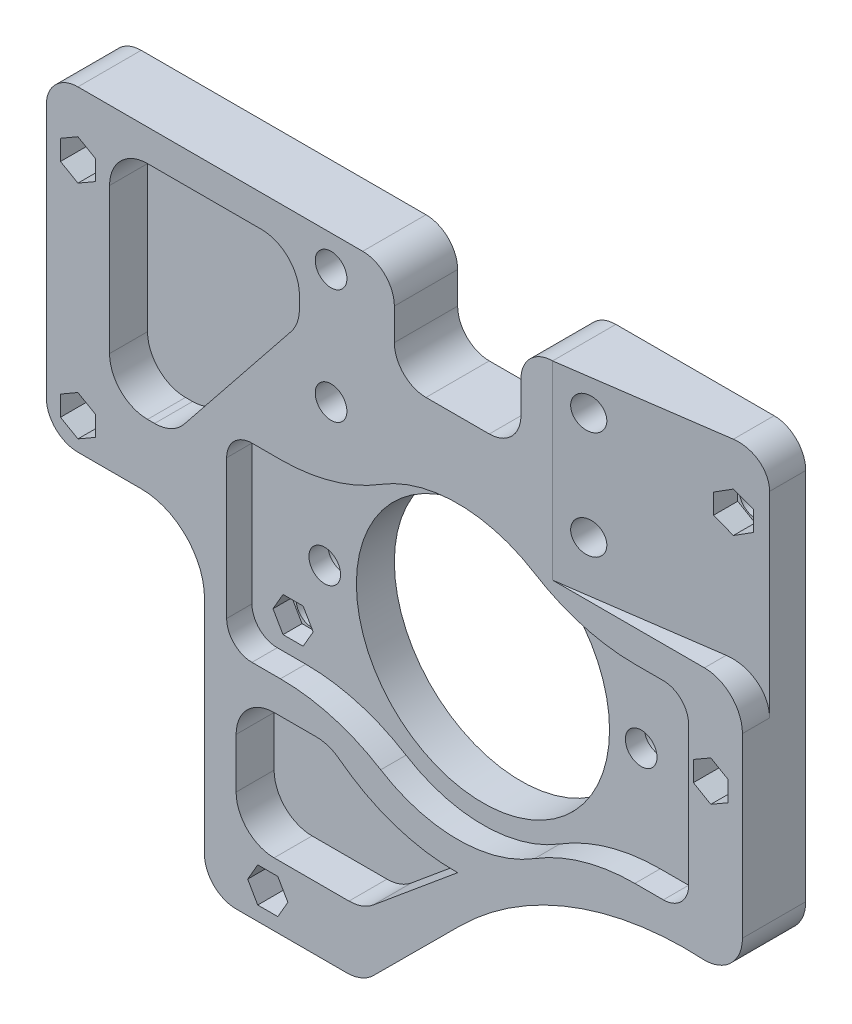
from build123d import *

# Parameters (mm, degrees)
SKETCH1_R           = 20
SKETCH1_R_2         = 2.5
BOSS_EXTRUDE1_DEPTH = 10
CUT_EXTRUDE1_DEPTH  = 30
FILLET1_R           = 6
CUT_EXTRUDE2_DEPTH  = 4
CUT_EXTRUDE3_DEPTH  = 6
SKETCH5_R           = 3.75
CUT_EXTRUDE4_DEPTH  = 3
CUT_EXTRUDE5_DEPTH  = 5
CUT_EXTRUDE6_DEPTH  = 7


with BuildPart() as part:
    # Sketch1 → Boss-Extrude1 (new body)
    with BuildSketch(Plane.XY):
        with BuildLine():
            Line((0, 5), (0, 40))
            ThreePointArc((0, 40), (-2.928932188, 47.071067812), (-10, 50))
            Line((-10, 50), (-20, 50))
            ThreePointArc((-20, 50), (-23.535533906, 51.464466094), (-25, 55))
            Line((-25, 55), (-25, 95))
            ThreePointArc((-25, 95), (-23.535533906, 98.535533906), (-20, 100))
            Line((-20, 100), (25, 100))
            ThreePointArc((25, 100), (28.535533906, 98.535533906), (30, 95))
            Line((30, 95), (30, 90))
            ThreePointArc((30, 90), (31.464466094, 86.464466094), (35, 85))
            Line((35, 85), (45, 85))
            ThreePointArc((45, 85), (48.535533906, 86.464466094), (50, 90))
            Line((50, 90), (50, 95))
            ThreePointArc((50, 95), (51.464466094, 98.535533906), (55, 100))
            Line((55, 100), (80, 100))
            ThreePointArc((80, 100), (83.535533906, 98.535533906), (85, 95))
            Line((85, 95), (85, 36))
            ThreePointArc((85, 36), (83.242640687, 31.757359313), (79, 30))
            ThreePointArc((79, 30), (58.114182378, 26.808820785), (40.36, 15.355))
            Line((40.36, 15.355), (26.706048875, 1.749781342))
            ThreePointArc((26.706048875, 1.749781342), (24.762144416, 0.4546726), (22.470999719, 0))
            Line((22.470999719, 0), (5, 0))
            ThreePointArc((5, 0), (1.464466094, 1.464466094), (0, 5))
        make_face()
        with Locations((40, 50)):
            Circle(SKETCH1_R, mode=Mode.SUBTRACT)
        with Locations((10, 5)):
            Circle(SKETCH1_R_2, mode=Mode.SUBTRACT)
        with Locations((10, 40)):
            Circle(SKETCH1_R_2, mode=Mode.SUBTRACT)
        with Locations((15, 50)):
            Circle(SKETCH1_R_2, mode=Mode.SUBTRACT)
        with Locations((-20, 55)):
            Circle(SKETCH1_R_2, mode=Mode.SUBTRACT)
        with Locations((-20, 90)):
            Circle(SKETCH1_R_2, mode=Mode.SUBTRACT)
        with Locations((20, 95)):
            Circle(SKETCH1_R_2, mode=Mode.SUBTRACT)
        with Locations((20, 76.86)):
            Circle(SKETCH1_R_2, mode=Mode.SUBTRACT)
        with Locations((60, 77.99)):
            Circle(SKETCH1_R_2, mode=Mode.SUBTRACT)
        with Locations((60, 95)):
            Circle(SKETCH1_R_2, mode=Mode.SUBTRACT)
        with Locations((80, 90)):
            Circle(SKETCH1_R_2, mode=Mode.SUBTRACT)
        with Locations((80, 55)):
            Circle(SKETCH1_R_2, mode=Mode.SUBTRACT)
        with Locations((65, 50)):
            Circle(SKETCH1_R_2, mode=Mode.SUBTRACT)
    extrude(amount=BOSS_EXTRUDE1_DEPTH)

    # Sketch2 → Cut-Extrude1 (cut)
    with BuildSketch(Plane(origin=(0, 100, 0), x_dir=(1, 0, 0), z_dir=(0, 1, 0))):
        Polygon((55, -10), (85, -5.7143), (85, -10), align=None)
    extrude(amount=-CUT_EXTRUDE1_DEPTH, mode=Mode.SUBTRACT)

    # Fillet1
    fillet1_edges = [part.edges().sort_by_distance(p)[0] for p in [
        (85, 70, 7.85715),
    ]]
    fillet(fillet1_edges, radius=FILLET1_R)

    # Sketch3 → Cut-Extrude2 (cut)
    with BuildSketch(Plane.XY.offset(10)):
        with BuildLine():
            Line((76.5, 61), (76.5, 39))
            ThreePointArc((76.5, 39), (75.328427125, 36.171572875), (72.5, 35))
            Line((72.5, 35), (68, 35))
            ThreePointArc((68, 35), (59.758366163, 33.845718429), (52.150943396, 30.471698113))
            ThreePointArc((52.150943396, 30.471698113), (40, 27), (27.849056604, 30.471698113))
            ThreePointArc((27.849056604, 30.471698113), (20.241633837, 33.845718429), (12, 35))
            Line((12, 35), (7.5, 35))
            ThreePointArc((7.5, 35), (4.671572875, 36.171572875), (3.5, 39))
            Line((3.5, 39), (3.5, 61))
            ThreePointArc((3.5, 61), (4.671572875, 63.828427125), (7.5, 65))
            Line((7.5, 65), (12, 65))
            ThreePointArc((12, 65), (20.241633837, 66.154281571), (27.849056604, 69.528301887))
            ThreePointArc((27.849056604, 69.528301887), (40, 73), (52.150943396, 69.528301887))
            ThreePointArc((52.150943396, 69.528301887), (59.758366163, 66.154281571), (68, 65))
            Line((68, 65), (72.5, 65))
            ThreePointArc((72.5, 65), (75.328427125, 63.828427125), (76.5, 61))
        make_face()
    extrude(amount=-CUT_EXTRUDE2_DEPTH, mode=Mode.SUBTRACT)

    # Sketch4 → Cut-Extrude3 (cut)
    with BuildSketch(Plane.XY.offset(10)):
        with BuildLine():
            Line((-15, 66), (-15, 89))
            ThreePointArc((-15, 89), (-13.242640687, 93.242640687), (-9, 95))
            Line((-9, 95), (9, 95))
            ThreePointArc((9, 95), (13.242640687, 93.242640687), (15, 89))
            Line((15, 89), (15, 87.10469))
            ThreePointArc((15, 87.10469), (14.661769972, 85.118648515), (13.685213073, 83.356519985))
            Line((13.685213073, 83.356519985), (-3.198536927, 62.251829985))
            ThreePointArc((-3.198536927, 62.251829985), (-5.284617461, 60.592180657), (-7.88375, 60))
            Line((-7.88375, 60), (-9, 60))
            ThreePointArc((-9, 60), (-13.242640687, 61.757359313), (-15, 66))
        make_face()
        with BuildLine():
            Line((5, 23.8912), (5, 16))
            ThreePointArc((5, 16), (6.757359313, 11.757359313), (11, 10))
            Line((11, 10), (22.83171, 10))
            ThreePointArc((22.83171, 10), (24.870928608, 10.357164944), (26.667368083, 11.386137511))
            Line((26.667368083, 11.386137511), (40, 22.47))
            ThreePointArc((40, 22.47), (30.130642928, 23.984324498), (21.304906792, 28.653775146))
            ThreePointArc((21.304906792, 28.653775146), (19.582266385, 29.573428915), (17.65554, 29.8912))
            Line((17.65554, 29.8912), (11, 29.8912))
            ThreePointArc((11, 29.8912), (6.757359313, 28.133840687), (5, 23.8912))
        make_face()
    extrude(amount=-CUT_EXTRUDE3_DEPTH, mode=Mode.SUBTRACT)

    # Sketch5 → Cut-Extrude4 (cut)
    with BuildSketch(Plane(origin=(0, 0, 0), x_dir=(-1, 0, 0), z_dir=(0, 0, -1))):
        with Locations((-65, 50)):
            Circle(SKETCH5_R)
        with Locations((-15, 50)):
            Circle(SKETCH5_R)
    extrude(amount=-CUT_EXTRUDE4_DEPTH, mode=Mode.SUBTRACT)

    # Sketch6 → Cut-Extrude5 (cut)
    with BuildSketch(Plane(origin=(0, 0, 0), x_dir=(-1, 0, 0), z_dir=(0, 0, -1))):
        Polygon((-56.824573519, 95), (-58.41228676, 97.75), (-61.58771324, 97.75), (-63.175426481, 95), (-61.58771324, 92.25), (-58.41228676, 92.25), align=None)
        Polygon((-56.824573519, 77.99), (-58.41228676, 80.74), (-61.58771324, 80.74), (-63.175426481, 77.99), (-61.58771324, 75.24), (-58.41228676, 75.24), align=None)
        Polygon((-16.824573519, 76.86), (-18.41228676, 79.61), (-21.58771324, 79.61), (-23.175426481, 76.86), (-21.58771324, 74.11), (-18.41228676, 74.11), align=None)
        Polygon((-16.824573519, 95), (-18.41228676, 97.75), (-21.58771324, 97.75), (-23.175426481, 95), (-21.58771324, 92.25), (-18.41228676, 92.25), align=None)
    extrude(amount=-CUT_EXTRUDE5_DEPTH, mode=Mode.SUBTRACT)

    # Sketch7 → Cut-Extrude6 (cut)
    with BuildSketch(Plane.XY.offset(10)):
        Polygon((-17.25, 91.58771324), (-20, 93.175426481), (-22.75, 91.58771324), (-22.75, 88.41228676), (-20, 86.824573519), (-17.25, 88.41228676), align=None)
        Polygon((-17.25, 56.58771324), (-20, 58.175426481), (-22.75, 56.58771324), (-22.75, 53.41228676), (-20, 51.824573519), (-17.25, 53.41228676), align=None)
        Polygon((82.75, 91.58771324), (80, 93.175426481), (77.25, 91.58771324), (77.25, 88.41228676), (80, 86.824573519), (82.75, 88.41228676), align=None)
        Polygon((82.75, 56.58771324), (80, 58.175426481), (77.25, 56.58771324), (77.25, 53.41228676), (80, 51.824573519), (82.75, 53.41228676), align=None)
        Polygon((13.175426481, 40), (11.58771324, 42.75), (8.41228676, 42.75), (6.824573519, 40), (8.41228676, 37.25), (11.58771324, 37.25), align=None)
        Polygon((13.175426481, 5), (11.58771324, 7.75), (8.41228676, 7.75), (6.824573519, 5), (8.41228676, 2.25), (11.58771324, 2.25), align=None)
    extrude(amount=-CUT_EXTRUDE6_DEPTH, mode=Mode.SUBTRACT)


solid = part.part
